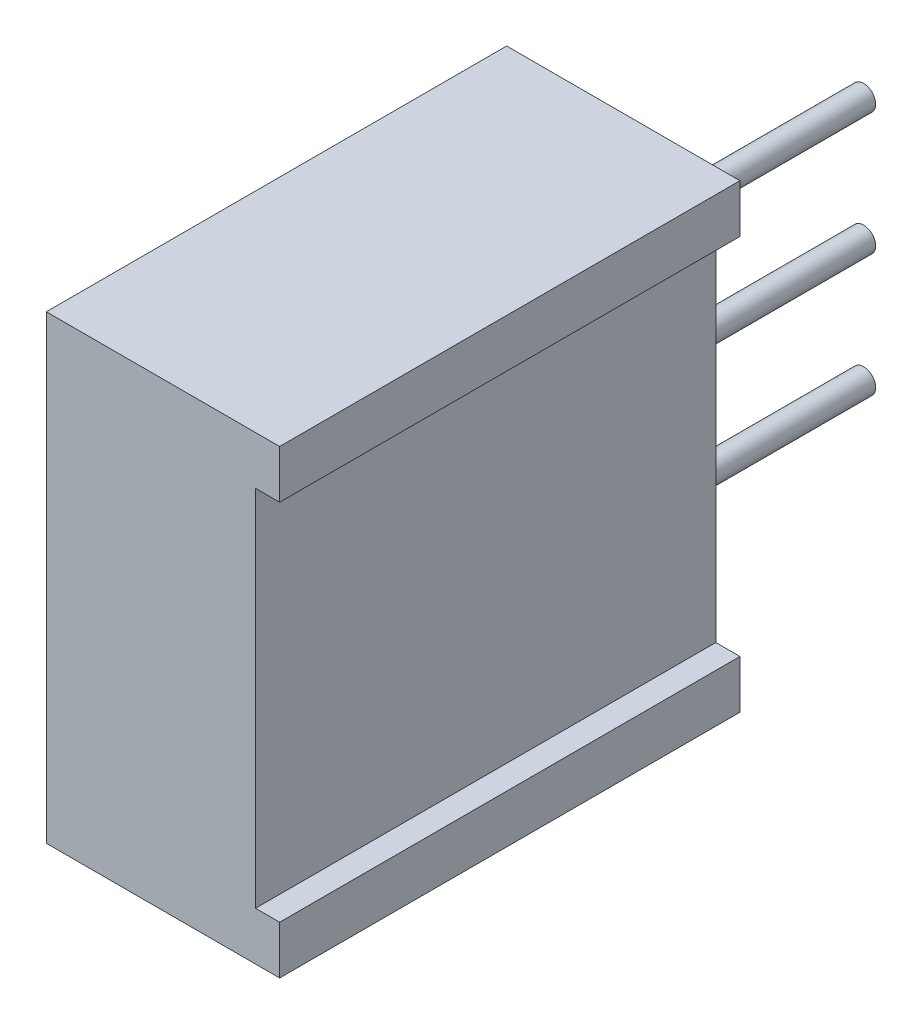
from build123d import *

# Parameters (mm, degrees)
SKETCH1_W           = 9.53
SKETCH1_H           = 9.53
BASIC_SHAPE_DEPTH   = 4.83
SKETCH3_R           = 2
ADJUSTER_DEPTH      = 0.1
ADJUSTER_SLOT_DEPTH = 1
SKETCH5_R           = 0.25
PINS_DEPTH          = 5
SKETCH6_W           = 0.5
SKETCH6_H           = 7.53
REAR_RELIEF_DEPTH   = 15.53


with BuildPart() as part:
    # Sketch1 → Basic Shape (new body)
    with BuildSketch(Plane(origin=(0, 0, 0), x_dir=(0, 0, 1), z_dir=(1, 0, 0))):
        with Locations((4.765, 4.765)):
            Rectangle(SKETCH1_W, SKETCH1_H)
    extrude(amount=BASIC_SHAPE_DEPTH)

    # Sketch3 → Adjuster (cut)
    with BuildSketch(Plane.YZ):
        with Locations((-4.765, 4.765)):
            Circle(SKETCH3_R)
    extrude(amount=ADJUSTER_DEPTH, mode=Mode.SUBTRACT)

    # Sketch4 → Adjuster Slot (cut)
    with BuildSketch(Plane(origin=(0.1, 0, 0), x_dir=(0, -1, 0), z_dir=(-1, 0, 0))):
        with BuildLine():
            Line((3.749246997, 6.487859784), (6.487859784, 3.749246997))
            ThreePointArc((6.487859784, 3.749246997), (6.179213562, 3.350786438), (5.780753003, 3.042140216))
            Line((5.780753003, 3.042140216), (3.042140216, 5.780753003))
            ThreePointArc((3.042140216, 5.780753003), (3.350786438, 6.179213562), (3.749246997, 6.487859784))
        make_face()
    extrude(amount=-ADJUSTER_SLOT_DEPTH, mode=Mode.SUBTRACT)

    # Sketch5 → Pins (add)
    with BuildSketch(Plane(origin=(0, -19.06, 0), x_dir=(0, -1, 0), z_dir=(0, 0, -1))):
        with Locations((-16.835, -2.39)):
            Circle(SKETCH5_R)
        with Locations((-14.295, -2.39)):
            Circle(SKETCH5_R)
        with Locations((-11.755, -2.39)):
            Circle(SKETCH5_R)
    extrude(amount=PINS_DEPTH)

    # Sketch6 → Rear Relief (cut, through all)
    with BuildSketch(Plane.XY.offset(9.53)):
        with Locations((4.58, -4.765)):
            Rectangle(SKETCH6_W, SKETCH6_H)
    extrude(amount=-REAR_RELIEF_DEPTH, mode=Mode.SUBTRACT)


solid = part.part
